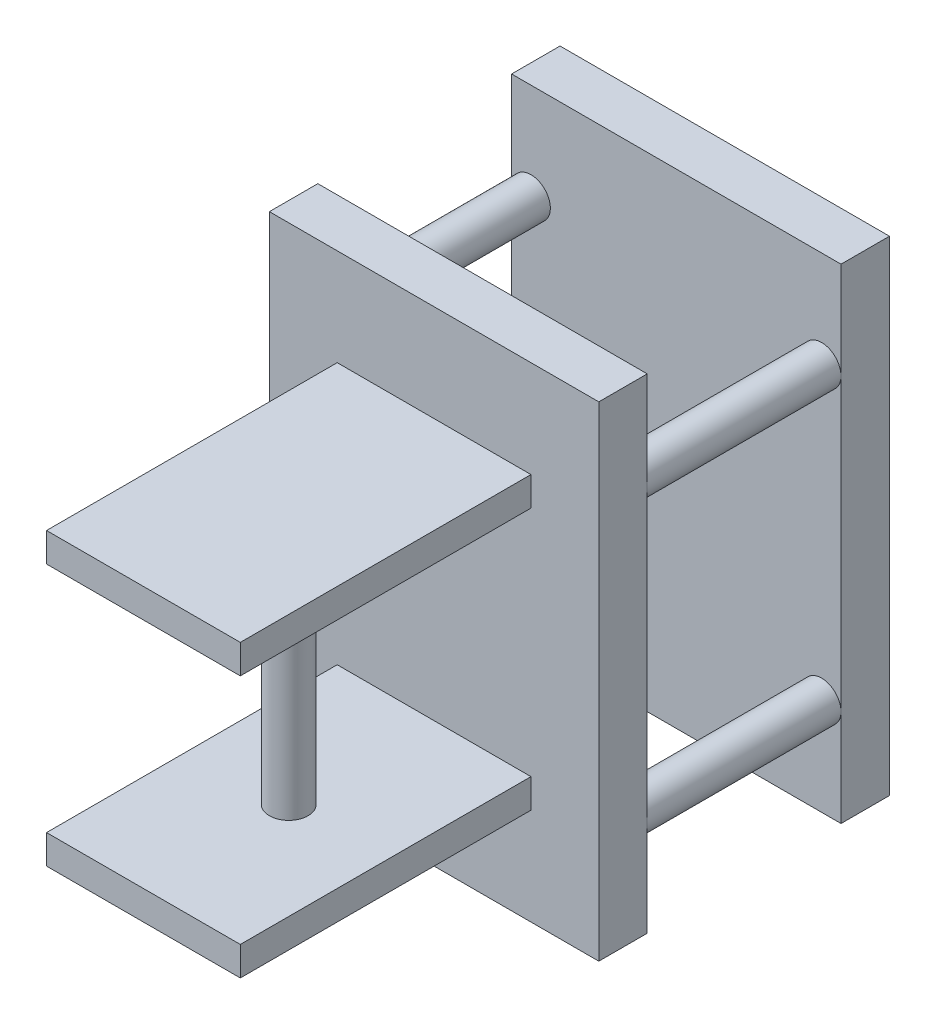
from build123d import *

# Parameters (mm, degrees)
SKETCH_1_W      = 34
SKETCH_1_H      = 50
EXTRUDE_1_DEPTH = 5
SKETCH_2_R      = 2
EXTRUDE_2_DEPTH = 20
SKETCH_3_W      = 34
SKETCH_3_H      = 50
EXTRUDE_3_DEPTH = 5
SKETCH_4_W      = 20
SKETCH_4_H      = 3
EXTRUDE_4_DEPTH = 30
SKETCH_5_R      = 2
EXTRUDE_5_DEPTH = 25


with BuildPart() as part:
    # 草图1 → 凸台-拉伸1 (new body)
    with BuildSketch(Plane.XY):
        with Locations((-4.949270059, 16.999651533)):
            Rectangle(SKETCH_1_W, SKETCH_1_H)
    extrude(amount=EXTRUDE_1_DEPTH)

    # 草图2 → 凸台-拉伸2 (add)
    with BuildSketch(Plane.XY.offset(5)):
        with Locations((-19.949270059, 31.999651533)):
            Circle(SKETCH_2_R)
        with Locations((-19.949270059, 1.999651533)):
            Circle(SKETCH_2_R)
        with Locations((10.050729941, 31.999651533)):
            Circle(SKETCH_2_R)
        with Locations((10.050729941, 1.999651533)):
            Circle(SKETCH_2_R)
    extrude(amount=EXTRUDE_2_DEPTH)

    # 草图3 → 凸台-拉伸3 (add)
    with BuildSketch(Plane.XY.offset(25)):
        with Locations((-4.949270059, 17.194555641)):
            Rectangle(SKETCH_3_W, SKETCH_3_H)
    extrude(amount=EXTRUDE_3_DEPTH)

    # 草图4 → 凸台-拉伸4 (add)
    with BuildSketch(Plane.XY.offset(30)):
        with Locations((-4.949270059, 30.694555641)):
            Rectangle(SKETCH_4_W, SKETCH_4_H)
        with Locations((-4.949270059, 3.694555641)):
            Rectangle(SKETCH_4_W, SKETCH_4_H)
    extrude(amount=EXTRUDE_4_DEPTH)

    # 草图5 → 凸台-拉伸5 (add)
    with BuildSketch(Plane(origin=(0, 5.194555641, 0), x_dir=(1, 0, 0), z_dir=(0, 1, 0))):
        with Locations((-4.949270059, -45)):
            Circle(SKETCH_5_R)
    extrude(amount=EXTRUDE_5_DEPTH)


solid = part.part
